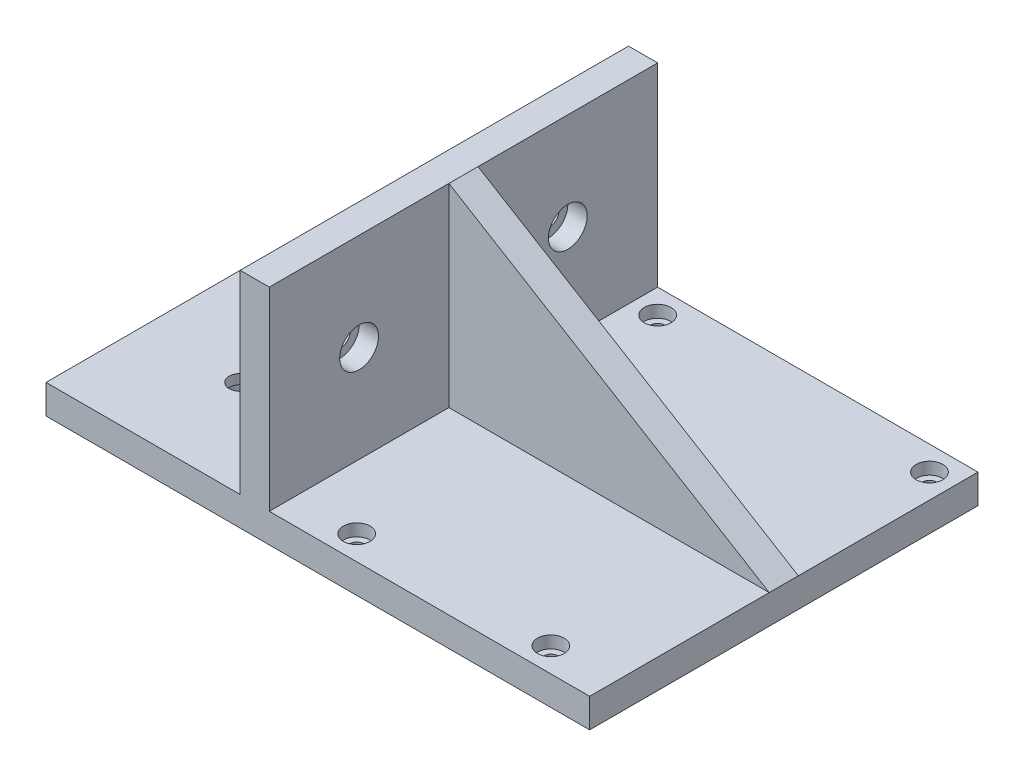
from build123d import *

# Parameters (mm, degrees)
SKETCH1_W                                = 66
SKETCH1_H                                = 80
BOSS_EXTRUDE1_DEPTH                      = 6
CBORE_FOR_M2_5_SHCS2_D                   = 2.9
CBORE_FOR_M2_5_SHCS2_CBORE_D             = 5.5
CBORE_FOR_M2_5_SHCS2_CBORE_DEPTH         = 2.5
BOSS_EXTRUDE2_DEPTH                      = 80
RIB1_REACH                               = 101.785
SKETCH5_WALL_W                           = 278.74466228
SKETCH5_WALL_H                           = 6
CBORE_FOR_M4_SHCS1_D                     = 4.5
CBORE_FOR_M4_SHCS1_CBORE_D               = 8
CBORE_FOR_M4_SHCS1_CBORE_DEPTH           = 4
CBORE_FOR_M4_SHCS1_ON_FACE_2_D           = 4.5
CBORE_FOR_M4_SHCS1_ON_FACE_2_CBORE_D     = 8
CBORE_FOR_M4_SHCS1_ON_FACE_2_CBORE_DEPTH = 4


with BuildPart() as part:
    # Sketch1 → Boss-Extrude1 (new body)
    with BuildSketch(Plane(origin=(0, 0, 0), x_dir=(1, 0, 0), z_dir=(0, 1, 0))):
        Rectangle(SKETCH1_W, SKETCH1_H)
    extrude(amount=BOSS_EXTRUDE1_DEPTH)

    # CBORE for M2.5 SHCS2 (through all)
    with Locations(Plane(origin=(0, 6, 0), x_dir=(1, 0, 0), z_dir=(0, 1, 0))):
        with Locations((20, -35), (-28, 35), (28, 35), (-20, -35)):
            CounterBoreHole(CBORE_FOR_M2_5_SHCS2_D / 2, CBORE_FOR_M2_5_SHCS2_CBORE_D / 2, CBORE_FOR_M2_5_SHCS2_CBORE_DEPTH)

    # Sketch4 → Boss-Extrude2 (add)
    with BuildSketch(Plane.XY.offset(40)):
        Polygon((-33, 0), (-33, 46), (-39, 46), (-39, 6), (-79, 6), (-79, 0), align=None)
    extrude(amount=-BOSS_EXTRUDE2_DEPTH)

    # Sketch5 wall → Rib1 (add, up to next)
    with BuildSketch(Plane(origin=(0, 26, 0), x_dir=(0.855197831554, -0.518301716093, 0), z_dir=(0.518301716093, 0.855197831554, 0)), mode=Mode.PRIVATE) as rib1_sk1:
        Rectangle(SKETCH5_WALL_W, SKETCH5_WALL_H)
    rib1_tool1 = extrude(rib1_sk1.sketch, amount=-RIB1_REACH, mode=Mode.PRIVATE) - part.part
    add(rib1_tool1.solids().sort_by_distance((0, 26, 0))[0])

    # CBORE for M4 SHCS1 (through all)
    with Locations(Plane(origin=(-59, 0, -20), x_dir=(0, 0, -1), z_dir=(0, -1, 0))):
        with Locations((0, 0), (-40, 0)):
            CounterBoreHole(CBORE_FOR_M4_SHCS1_D / 2, CBORE_FOR_M4_SHCS1_CBORE_D / 2, CBORE_FOR_M4_SHCS1_CBORE_DEPTH)

    # CBORE for M4 SHCS1 on face 2 (through all)
    with Locations(Plane(origin=(-33, 26, -21.5), x_dir=(0, 0, 1), z_dir=(1, 0, 0))):
        with Locations((0, 0), (43, 0)):
            CounterBoreHole(CBORE_FOR_M4_SHCS1_ON_FACE_2_D / 2, CBORE_FOR_M4_SHCS1_ON_FACE_2_CBORE_D / 2, CBORE_FOR_M4_SHCS1_ON_FACE_2_CBORE_DEPTH)


solid = part.part
